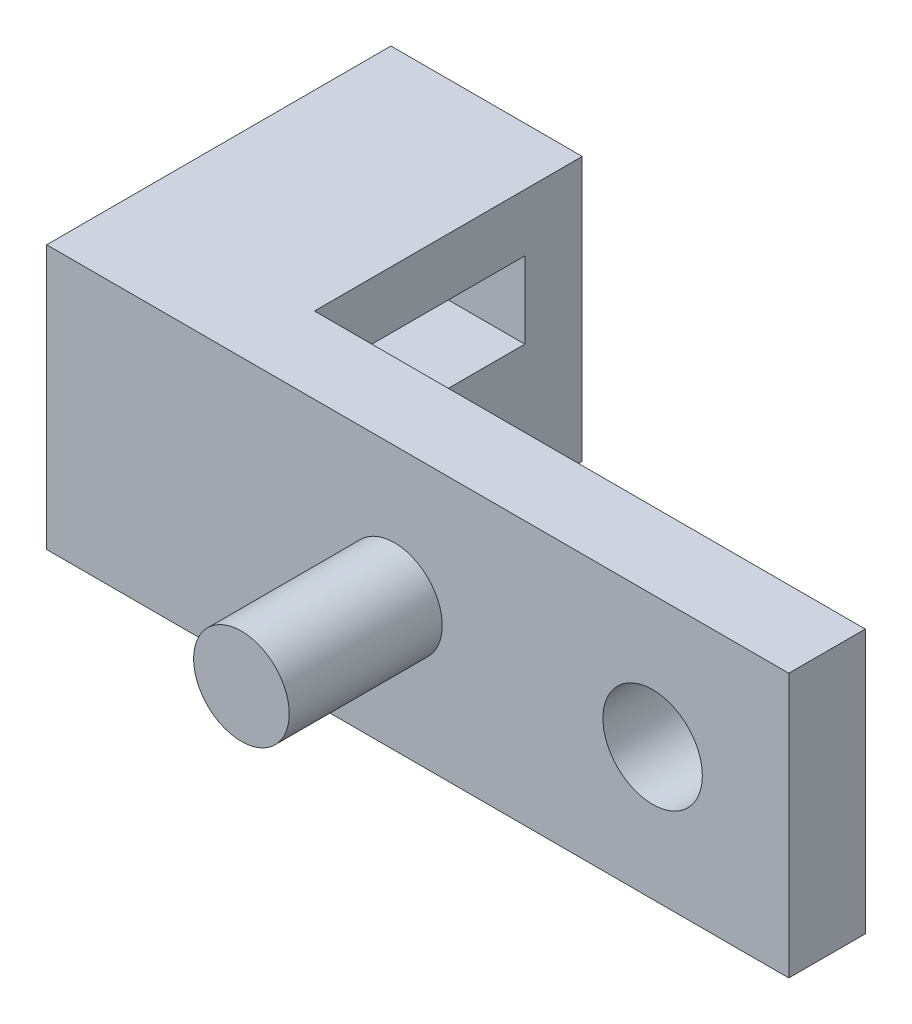
from build123d import *

# Parameters (mm, degrees)
BOSS_EXTRUDE1_DEPTH = 6.9
SKETCH2_R           = 1.3
CUT_EXTRUDE1_DEPTH  = 10
SKETCH3_R           = 1.25
BOSS_EXTRUDE2_DEPTH = 4
SKETCH4_W           = 4
SKETCH4_H           = 2
CUT_EXTRUDE2_DEPTH  = 6


with BuildPart() as part:
    # Sketch1 → Boss-Extrude1 (new body)
    with BuildSketch(Plane(origin=(0, 0, 0), x_dir=(1, 0, 0), z_dir=(0, 1, 0))):
        Polygon((154.749006664, -21.005499154), (135.349006664, -21.005499154), (135.349006664, -12.005499154), (140.349006664, -12.005499154), (140.349006664, -19.005499154), (154.749006664, -19.005499154), align=None)
    extrude(amount=BOSS_EXTRUDE1_DEPTH)

    # Sketch2 → Cut-Extrude1 (cut, through all)
    with BuildSketch(Plane.XY.offset(21.005499154)):
        with Locations((151.189006664, 3.45)):
            Circle(SKETCH2_R)
    extrude(amount=-CUT_EXTRUDE1_DEPTH, mode=Mode.SUBTRACT)

    # Sketch3 → Boss-Extrude2 (add)
    with BuildSketch(Plane.XY.offset(21.005499154)):
        with Locations((144.439006664, 3.45)):
            Circle(SKETCH3_R)
    extrude(amount=BOSS_EXTRUDE2_DEPTH)

    # Sketch4 → Cut-Extrude2 (cut, through all)
    with BuildSketch(Plane(origin=(140.349006664, 0, 0), x_dir=(0, 0, -1), z_dir=(1, 0, 0))):
        with Locations((-15.505499154, 4.4)):
            Rectangle(SKETCH4_W, SKETCH4_H)
    extrude(amount=-CUT_EXTRUDE2_DEPTH, mode=Mode.SUBTRACT)


solid = part.part
